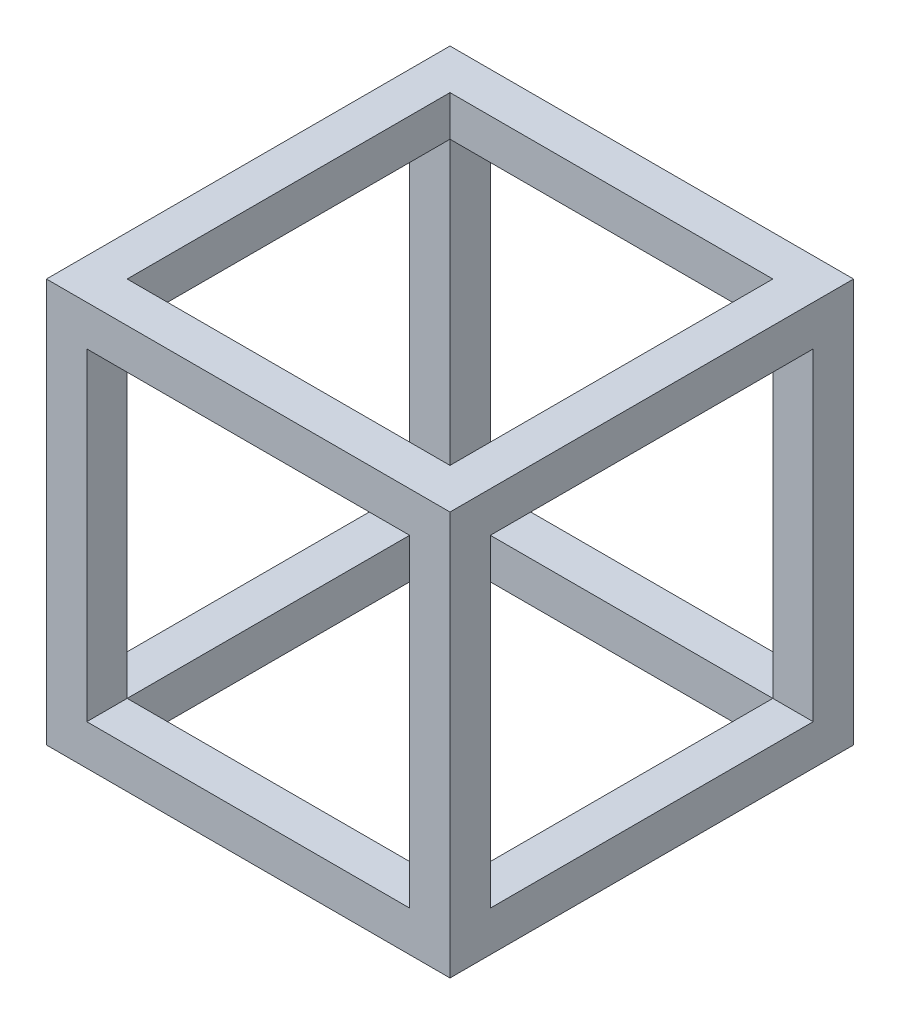
from build123d import *

# Parameters (mm, degrees)
SZKIC2_W                    = 100
SZKIC2_H                    = 100
DODANIE_WYCI_GNI_CIE1_DEPTH = 100
SZKIC3_W                    = 80
SZKIC3_H                    = 80
WYTNIJ_WYCI_GNI_CIE1_DEPTH  = 101
SZKIC4_W                    = 80
SZKIC4_H                    = 80
WYTNIJ_WYCI_GNI_CIE2_DEPTH  = 101
SZKIC6_W                    = 80
SZKIC6_H                    = 80
WYTNIJ_WYCI_GNI_CIE3_DEPTH  = 101


with BuildPart() as part:
    # Szkic2 → Dodanie-wyciągnięcie1 (new body)
    with BuildSketch(Plane.XY):
        with Locations((50, 50)):
            Rectangle(SZKIC2_W, SZKIC2_H)
    extrude(amount=DODANIE_WYCI_GNI_CIE1_DEPTH)

    # Szkic3 → Wytnij-wyciągnięcie1 (cut, through all)
    with BuildSketch(Plane.XY.offset(100)):
        with Locations((50, 50)):
            Rectangle(SZKIC3_W, SZKIC3_H)
    extrude(amount=-WYTNIJ_WYCI_GNI_CIE1_DEPTH, mode=Mode.SUBTRACT)

    # Szkic4 → Wytnij-wyciągnięcie2 (cut, through all)
    with BuildSketch(Plane(origin=(100, 0, 0), x_dir=(0, 0, -1), z_dir=(1, 0, 0))):
        with Locations((-50, 50)):
            Rectangle(SZKIC4_W, SZKIC4_H)
    extrude(amount=-WYTNIJ_WYCI_GNI_CIE2_DEPTH, mode=Mode.SUBTRACT)

    # Szkic6 → Wytnij-wyciągnięcie3 (cut, through all)
    with BuildSketch(Plane(origin=(0, 100, 0), x_dir=(1, 0, 0), z_dir=(0, 1, 0))):
        with Locations((50, -50)):
            Rectangle(SZKIC6_W, SZKIC6_H)
    extrude(amount=-WYTNIJ_WYCI_GNI_CIE3_DEPTH, mode=Mode.SUBTRACT)


solid = part.part
